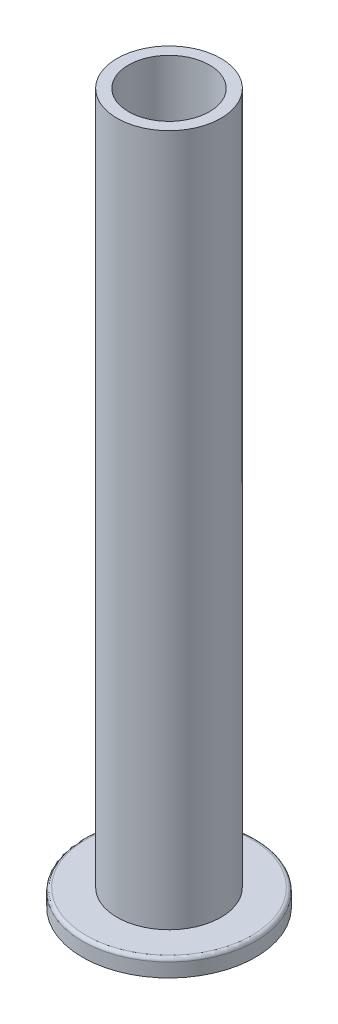
from build123d import *

# Parameters (mm, degrees)
FILLET2_R          = 1
SKETCH2_R          = 11.696559432
CUT_EXTRUDE1_DEPTH = 206


with BuildPart() as part:
    # Sketch1 → Revolve1 (revolve)
    with BuildSketch(Plane.XY):
        Polygon((0, 0), (0, 200), (15, 200), (15, 0), (25, 0), (25, -5), (0, -5), align=None)
    revolve(axis=Axis((0, 0, 0), (0, 1, 0)))

    # Fillet2
    fillet2_edges = [part.edges().sort_by_distance(p)[0] for p in [
        (-25, 0, 0),
    ]]
    fillet(fillet2_edges, radius=FILLET2_R)

    # Sketch2 → Cut-Extrude1 (cut, through all)
    with BuildSketch(Plane(origin=(0, 200, 0), x_dir=(1, 0, 0), z_dir=(0, 1, 0))):
        Circle(SKETCH2_R)
    extrude(amount=-CUT_EXTRUDE1_DEPTH, mode=Mode.SUBTRACT)


solid = part.part
